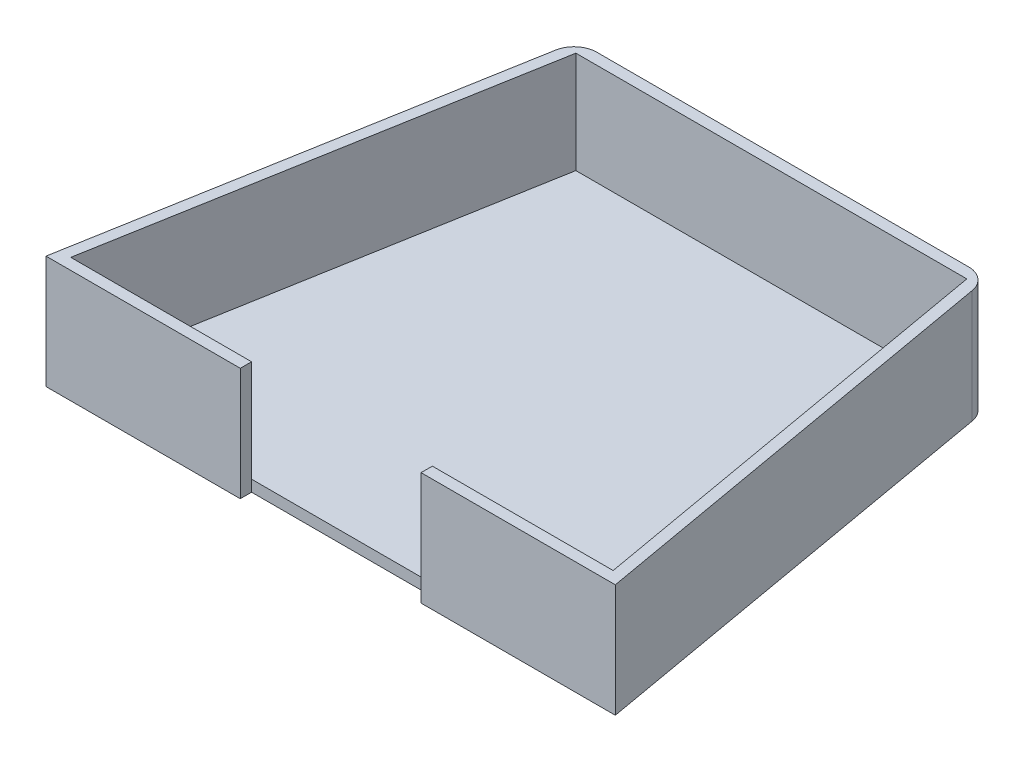
from build123d import *

# Parameters (mm, degrees)
EXTRUDE_THIN1_DEPTH = 50
BOSS_EXTRUDE1_DEPTH = 5
FILLET1_R           = 10
SKETCH2_W           = 80
SKETCH2_H           = 50
CUT_EXTRUDE1_DEPTH  = 5


with BuildPart() as part:
    # Sketch1 → Extrude-Thin1 (new body)
    with BuildSketch(Plane(origin=(0, 0, 0), x_dir=(1, 0, 0), z_dir=(0, 1, 0))):
        Polygon((245.958767963, -5), (-5.958767963, -5), (29.306628179, 195), (210.693371821, 195), align=None)
        Polygon((240, 0), (0, 0), (33.502126335, 190), (206.497873665, 190), align=None, mode=Mode.SUBTRACT)
    extrude(amount=EXTRUDE_THIN1_DEPTH)

    # Fillet1
    fillet1_edges = [part.edges().sort_by_distance(p)[0] for p in [
        (210.693371821, 25, -195),
        (29.306628179, 25, -195),
    ]]
    fillet(fillet1_edges, radius=FILLET1_R)

    # Sketch2 → Cut-Extrude1 (cut)
    with BuildSketch(Plane.XY.offset(5)):
        with Locations((120, 25)):
            Rectangle(SKETCH2_W, SKETCH2_H)
    extrude(amount=-CUT_EXTRUDE1_DEPTH, mode=Mode.SUBTRACT)


with BuildPart() as body_2:
    # Sketch1_3 → Boss-Extrude1 (new body)
    with BuildSketch(Plane(origin=(0, 0, 0), x_dir=(1, 0, 0), z_dir=(0, 1, 0))):
        Polygon((0, 0), (33.502126335, 190), (206.497873665, 190), (240, 0), align=None)
    extrude(amount=BOSS_EXTRUDE1_DEPTH)


solid = Compound([part.part, body_2.part])
